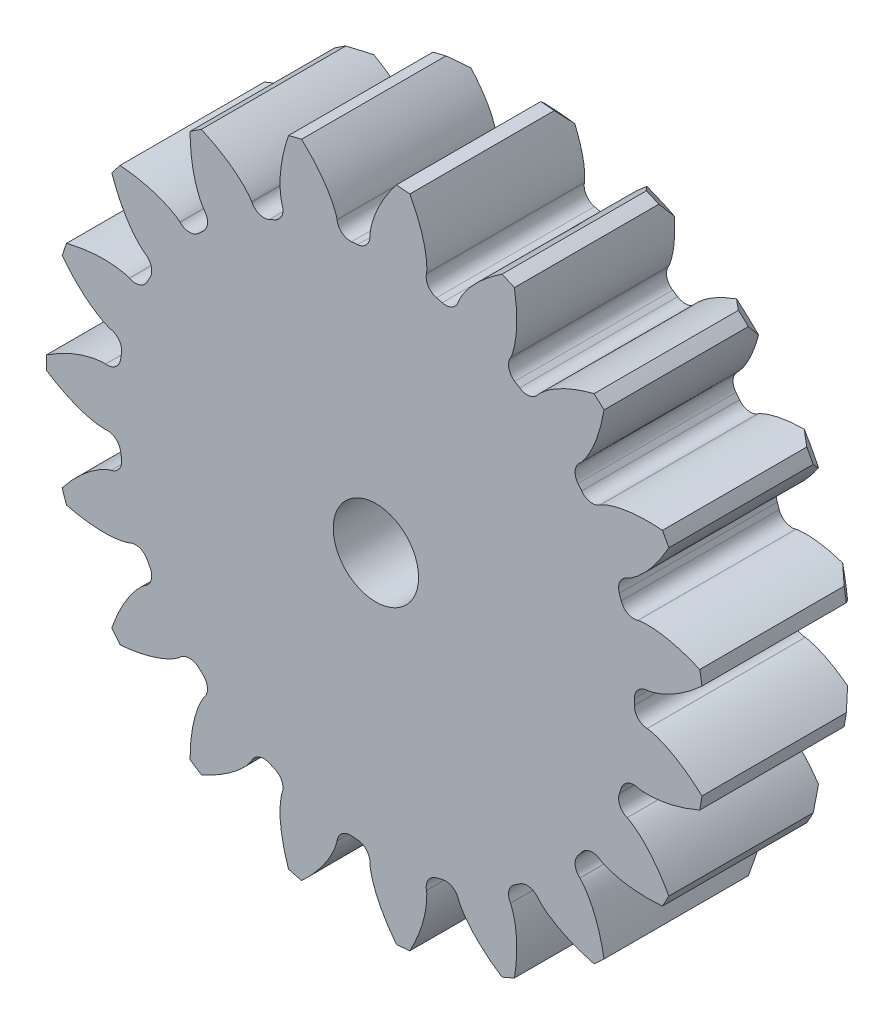
from build123d import *

# Parameters (mm, degrees)
SKETCH1_R                = 10.5
BOSS_EXTRUDE1_DEPTH      = 5
CUT_EXTRUDE1_DEPTH       = 16.668439616
FILLET1_R                = 0.355654565
FILLET2_R                = 0.355654565
CIRPATTERN1_COUNT        = 19
FILLET1_OF_CIRPATTERN1_R = 0.355654565
FILLET2_OF_CIRPATTERN1_R = 0.355654565
SKETCH4_R                = 1.35
BORE_DEPTH               = 16.656347018
SKETCH5_R                = 21
TOLERANCE_DEPTH          = 16.656347018


with BuildPart() as part:
    # Sketch1 → Boss-Extrude1 (new body)
    with BuildSketch(Plane.XY):
        Circle(SKETCH1_R)
    extrude(amount=BOSS_EXTRUDE1_DEPTH)

    # Sketch2 → Cut-Extrude1 (cut, through all)
    with BuildSketch(Plane.XY.offset(5)):
        with BuildLine():
            Line((8.238547136, 0.434558502), (8.597971457, 0.45351705))
            add(Edge.make_bspline(
                [(8.597971457, 0.45351705), (8.601066166, 0.453726154), (8.609736191, 0.454454149), (8.626084978, 0.45638906), (8.652681425, 0.460337865), (8.701902798, 0.469368327), (8.760584055, 0.482995815), (8.826391795, 0.501123817), (8.896585541, 0.523329462), (8.956241339, 0.543998434), (9.015389578, 0.566175785), (9.073967367, 0.589669509), (9.144489943, 0.619774692), (9.228431798, 0.658157785), (9.325567082, 0.706321248), (9.434519939, 0.764819582), (9.5441621, 0.828535043), (9.650866717, 0.894583196), (9.75722015, 0.965119417), (9.859083036, 1.036059663), (9.963278973, 1.113575273), (10.058647067, 1.187080808), (10.163607324, 1.273605914), (10.247769209, 1.34465728), (10.333065488, 1.421484929), (10.37433401, 1.459381335), (10.395319963, 1.478960066)],
                knots=[0, 0, 0, 0, 0, 0.005376749, 0.015083688, 0.02853182, 0.04661014, 0.092110525, 0.119476176, 0.146842496, 0.174208854, 0.201574956, 0.228941013, 0.256307345, 0.307035032, 0.361767352, 0.416499661, 0.471231937, 0.525964282, 0.580696616, 0.635428982, 0.690161387, 0.744893688, 0.799626082, 0.854358408, 0.909090915, 0.909090915, 0.909090915, 0.909090915, 0.909090915], degree=4))
            ThreePointArc((10.395319963, 1.478960066), (10.5, 0), (10.395319963, -1.478960066))
            add(Edge.make_bspline(
                [(8.597971457, -0.45351705), (8.601066166, -0.453726154), (8.609736191, -0.454454149), (8.626084978, -0.45638906), (8.652681425, -0.460337865), (8.701902798, -0.469368327), (8.760584055, -0.482995815), (8.826391795, -0.501123817), (8.896585541, -0.523329462), (8.956241339, -0.543998434), (9.015389578, -0.566175785), (9.073967367, -0.589669509), (9.144489943, -0.619774692), (9.228431798, -0.658157785), (9.325567082, -0.706321248), (9.434519939, -0.764819582), (9.5441621, -0.828535043), (9.650866717, -0.894583196), (9.75722015, -0.965119417), (9.859083036, -1.036059663), (9.963278973, -1.113575273), (10.058647067, -1.187080808), (10.163607324, -1.273605914), (10.247769209, -1.34465728), (10.333065488, -1.421484929), (10.37433401, -1.459381335), (10.395319963, -1.478960066)],
                knots=[0, 0, 0, 0, 0, 0.005376749, 0.015083688, 0.02853182, 0.04661014, 0.092110525, 0.119476176, 0.146842496, 0.174208854, 0.201574956, 0.228941013, 0.256307345, 0.307035032, 0.361767352, 0.416499661, 0.471231937, 0.525964282, 0.580696616, 0.635428982, 0.690161387, 0.744893688, 0.799626082, 0.854358408, 0.909090915, 0.909090915, 0.909090915, 0.909090915, 0.909090915], degree=4))
            Line((8.597971457, -0.45351705), (8.238547136, -0.434558502))
            ThreePointArc((8.238547136, -0.434558502), (8.25, 0), (8.238547136, 0.434558502))
        make_face()
    cut_extrude1 = extrude(amount=-CUT_EXTRUDE1_DEPTH, mode=Mode.SUBTRACT)

    # Fillet1
    fillet1_edges = [part.edges().sort_by_distance(p)[0] for p in [
        (8.238547136, 0.434558502, 2.5),
    ]]
    fillet(fillet1_edges, radius=FILLET1_R)

    # Fillet2
    fillet2_edges = [part.edges().sort_by_distance(p)[0] for p in [
        (8.238547136, -0.434558502, 2.5),
    ]]
    fillet(fillet2_edges, radius=FILLET2_R)

    # CirPattern1: Cut-Extrude1 ×19 about axis
    cirpattern1_axis = Axis((0, 0, 5), (0, 0, -1))
    for i in range(1, CIRPATTERN1_COUNT):
        add(cut_extrude1.rotate(cirpattern1_axis, i * 360 / CIRPATTERN1_COUNT), mode=Mode.SUBTRACT)

    # Fillet1 of CirPattern1
    fillet1_of_cirpattern1_edges = [part.edges().sort_by_distance(p)[0] for p in [
        (7.933260843, -2.264038958, 2.5),
        (6.76828264, -4.717292667, 2.5),
        (4.869855992, -6.659354519, 2.5),
        (2.443704884, -7.879771979, 2.5),
        (-0.247259566, -8.246293877, 2.5),
        (-2.911429605, -7.719201879, 2.5),
        (-5.260101071, -6.355614582, 2.5),
        (-7.038758968, -4.303297828, 2.5),
        (-8.054658112, -1.784651981, 2.5),
        (-8.19771007, 0.9273886, 2.5),
        (-7.45241294, 3.538932236, 2.5),
        (-5.899531233, 5.766977652, 2.5),
        (-3.707343775, 7.370081555, 2.5),
        (-1.113408095, 8.174522764, 2.5),
        (1.601182629, 8.09312759, 2.5),
        (4.142260371, 7.134716464, 2.5),
        (6.234459927, 5.403148103, 2.5),
        (7.651059013, 3.086064806, 2.5),
    ]]
    fillet(fillet1_of_cirpattern1_edges, radius=FILLET1_OF_CIRPATTERN1_R)

    # Fillet2 of CirPattern1
    fillet2_of_cirpattern1_edges = [part.edges().sort_by_distance(p)[0] for p in [
        (7.651059013, -3.086064806, 2.5),
        (6.234459927, -5.403148103, 2.5),
        (4.142260371, -7.134716464, 2.5),
        (1.601182629, -8.09312759, 2.5),
        (-1.113408095, -8.174522764, 2.5),
        (-3.707343775, -7.370081555, 2.5),
        (-5.899531233, -5.766977652, 2.5),
        (-7.45241294, -3.538932236, 2.5),
        (-8.19771007, -0.9273886, 2.5),
        (-8.054658112, 1.784651981, 2.5),
        (-7.038758968, 4.303297828, 2.5),
        (-5.260101071, 6.355614582, 2.5),
        (-2.911429605, 7.719201879, 2.5),
        (-0.247259566, 8.246293877, 2.5),
        (2.443704884, 7.879771979, 2.5),
        (4.869855992, 6.659354519, 2.5),
        (6.76828264, 4.717292667, 2.5),
        (7.933260843, 2.264038958, 2.5),
    ]]
    fillet(fillet2_of_cirpattern1_edges, radius=FILLET2_OF_CIRPATTERN1_R)

    # Sketch4 → Bore (cut, through all)
    with BuildSketch(Plane.XY.offset(5)):
        Circle(SKETCH4_R)
    extrude(amount=-BORE_DEPTH, mode=Mode.SUBTRACT)

    # Sketch5 → TOLERANCE (cut, through all)
    with BuildSketch(Plane.XY.offset(5)):
        Circle(SKETCH5_R)
        with BuildLine():
            Line((8.298039786, 2.295346858), (8.287400812, 2.292310648))
            ThreePointArc((8.287400812, 2.292310648), (7.971493069, 2.325401646), (7.766453609, 2.567995002))
            ThreePointArc((7.766453609, 2.567995002), (7.736785037, 2.656041658), (7.706118334, 2.743745655))
            ThreePointArc((7.706118334, 2.743745655), (7.718919354, 3.061123743), (7.94789004, 3.281271742))
            Line((7.94789004, 3.281271742), (7.958150564, 3.285410338))
            add(Edge.make_bspline(
                [(7.958150564, 3.285410338), (7.997359223, 3.302019925), (8.032960577, 3.324051928), (8.103780193, 3.368691785), (8.138229903, 3.392454909), (8.239536329, 3.466814827), (8.304462579, 3.520587408), (8.49120292, 3.688881504), (8.606043306, 3.811072511), (8.929053068, 4.19750903), (9.112816382, 4.479727113), (9.272799843, 4.774943253)],
                knots=[0, 0, 0, 0, 0.0625, 0.0625, 0.125, 0.125, 0.25, 0.25, 0.5, 0.5, 1, 1, 1, 1], degree=3))
            ThreePointArc((9.272799843, 4.774943253), (9.172911225, 4.964131309), (9.069163222, 5.151230771))
            add(Edge.make_bspline(
                [(9.069163222, 5.151230771), (8.734232229, 5.178789212), (8.397206051, 5.179237037), (7.897522299, 5.120219043), (7.731406922, 5.090702949), (7.488545768, 5.026376771), (7.368890833, 4.989276062), (7.252932669, 4.94189555), (7.176802326, 4.907040879), (7.138839803, 4.889328103), (7.103131195, 4.865347748)],
                knots=[0, 0, 0, 0, 0.5, 0.5, 0.75, 0.75, 0.875, 0.9375, 0.9375, 1, 1, 1, 1], degree=3))
            Line((7.103131195, 4.865347748), (7.094054527, 4.859021579))
            ThreePointArc((7.094054527, 4.859021579), (6.784518906, 4.787744539), (6.511819117, 4.950617314))
            ThreePointArc((6.511819117, 4.950617314), (6.455169367, 5.02425999), (6.397686829, 5.09725448))
            ThreePointArc((6.397686829, 5.09725448), (6.306741758, 5.401592632), (6.451824242, 5.684159065))
            Line((6.451824242, 5.684159065), (6.460185023, 5.691405008))
            add(Edge.make_bspline(
                [(6.460185023, 5.691405008), (6.491876124, 5.719845673), (6.518394719, 5.752243661), (6.570882595, 5.817459899), (6.595749851, 5.851121275), (6.667422589, 5.954346309), (6.711371028, 6.026286863), (6.833348258, 6.24609681), (6.90229092, 6.398955784), (7.08232339, 6.869335205), (7.164493838, 7.195929784), (7.219952431, 7.527096844)],
                knots=[0, 0, 0, 0, 0.0625, 0.0625, 0.125, 0.125, 0.25, 0.25, 0.5, 0.5, 1, 1, 1, 1], degree=3))
            ThreePointArc((7.219952431, 7.527096844), (7.064046792, 7.673600388), (6.905169046, 7.816875363))
            add(Edge.make_bspline(
                [(6.905169046, 7.816875363), (6.579437327, 7.734188697), (6.260526749, 7.625180036), (5.807080352, 7.407112751), (5.659549424, 7.325258345), (5.450733833, 7.185560649), (5.349608713, 7.111618265), (5.255317909, 7.029153405), (5.194629811, 6.971467775), (5.164475532, 6.942388315), (5.138488123, 6.908112716)],
                knots=[0, 0, 0, 0, 0.5, 0.5, 0.75, 0.75, 0.875, 0.9375, 0.9375, 1, 1, 1, 1], degree=3))
            Line((5.138488123, 6.908112716), (5.131957357, 6.899182126))
            ThreePointArc((5.131957357, 6.899182126), (4.862336848, 6.731261021), (4.551527981, 6.796763424))
            ThreePointArc((4.551527981, 6.796763424), (4.474035933, 6.848021792), (4.395966686, 6.89839669))
            ThreePointArc((4.395966686, 6.89839669), (4.211130833, 7.156715145), (4.256603177, 7.471079555))
            Line((4.256603177, 7.471079555), (4.262158194, 7.480647634))
            add(Edge.make_bspline(
                [(4.262158194, 7.480647634), (4.282897516, 7.517837389), (4.29745965, 7.557090538), (4.32592791, 7.635815966), (4.338517959, 7.675727861), (4.372790157, 7.796631978), (4.390998288, 7.878944629), (4.434994282, 8.126450608), (4.450568213, 8.293412907), (4.468114079, 8.796762321), (4.439787219, 9.132341806), (4.384711143, 9.463572697)],
                knots=[0, 0, 0, 0, 0.0625, 0.0625, 0.125, 0.125, 0.25, 0.25, 0.5, 0.5, 1, 1, 1, 1], degree=3))
            ThreePointArc((4.384711143, 9.463572697), (4.189683279, 9.551515797), (3.992892659, 9.635440219))
            add(Edge.make_bspline(
                [(3.992892659, 9.635440219), (3.7116583, 9.451468828), (3.445422231, 9.244816461), (3.087351142, 8.891330859), (2.974391929, 8.766008337), (2.822250311, 8.566077536), (2.750613482, 8.463306281), (2.688207909, 8.354693421), (2.649538553, 8.280427964), (2.630460202, 8.243133031), (2.617010131, 8.202276481)],
                knots=[0, 0, 0, 0, 0.5, 0.5, 0.75, 0.75, 0.875, 0.9375, 0.9375, 1, 1, 1, 1], degree=3))
            Line((2.617010131, 8.202276481), (2.613732978, 8.191709239))
            ThreePointArc((2.613732978, 8.191709239), (2.413245145, 7.945340926), (2.098008165, 7.906374753))
            ThreePointArc((2.098008165, 7.906374753), (2.008071285, 7.929694175), (1.917875342, 7.951990579))
            ThreePointArc((1.917875342, 7.951990579), (1.65917854, 8.136296524), (1.60011311, 8.44839265))
            Line((1.60011311, 8.44839265), (1.602260391, 8.459246014))
            add(Edge.make_bspline(
                [(1.602260391, 8.459246014), (1.609800505, 8.501154773), (1.610828146, 8.543009395), (1.612191813, 8.626712892), (1.611140327, 8.668550231), (1.60429806, 8.794031595), (1.59479275, 8.87779649), (1.55603986, 9.126177389), (1.516557382, 9.289150057), (1.369715277, 9.770923744), (1.233960764, 10.079122891), (1.074318368, 10.374523606)],
                knots=[0, 0, 0, 0, 0.0625, 0.0625, 0.125, 0.125, 0.25, 0.25, 0.5, 0.5, 1, 1, 1, 1], degree=3))
            ThreePointArc((1.074318368, 10.374523606), (0.861302573, 10.394376262), (0.647924397, 10.409855617))
            add(Edge.make_bspline(
                [(0.647924397, 10.409855617), (0.441663504, 10.144535657), (0.256952753, 9.862633575), (0.033059531, 9.412035305), (-0.033087084, 9.256825307), (-0.112067825, 9.018327005), (-0.146453401, 8.89786374), (-0.170211129, 8.774872768), (-0.182671319, 8.692075299), (-0.188606307, 8.650606377), (-0.188061516, 8.607596317)],
                knots=[0, 0, 0, 0, 0.5, 0.5, 0.75, 0.75, 0.875, 0.9375, 0.9375, 1, 1, 1, 1], degree=3))
            Line((-0.188061516, 8.607596317), (-0.187729926, 8.596537547))
            ThreePointArc((-0.187729926, 8.596537547), (-0.297359115, 8.298419857), (-0.582863391, 8.159207699))
            ThreePointArc((-0.582863391, 8.159207699), (-0.675499046, 8.152061153), (-0.768047555, 8.143862901))
            ThreePointArc((-0.768047555, 8.143862901), (-1.072571492, 8.234183928), (-1.229774041, 8.51019131))
            Line((-1.229774041, 8.51019131), (-1.231267187, 8.52115383))
            add(Edge.make_bspline(
                [(-1.231267187, 8.52115383), (-1.237743369, 8.563240128), (-1.250361582, 8.603160626), (-1.276250284, 8.682771618), (-1.290829359, 8.722000678), (-1.338044625, 8.838461435), (-1.374233328, 8.914601348), (-1.491535626, 9.136941241), (-1.581795973, 9.278263661), (-1.877113428, 9.686253968), (-2.105584486, 9.933674616), (-2.352493473, 10.161233904)],
                knots=[0, 0, 0, 0, 0.0625, 0.0625, 0.125, 0.125, 0.25, 0.25, 0.5, 0.5, 1, 1, 1, 1], degree=3))
            ThreePointArc((-2.352493473, 10.161233904), (-2.560413631, 10.110844774), (-2.767256528, 10.056201634))
            add(Edge.make_bspline(
                [(-2.767256528, 10.056201634), (-2.876192386, 9.738284638), (-2.959361543, 9.411681306), (-3.024814593, 8.912799683), (-3.036980598, 8.74452162), (-3.034241672, 8.493300809), (-3.027649785, 8.368199598), (-3.010185151, 8.244158494), (-2.995085919, 8.161801404), (-2.987234396, 8.120652295), (-2.972753779, 8.080149532)],
                knots=[0, 0, 0, 0, 0.5, 0.5, 0.75, 0.75, 0.875, 0.9375, 0.9375, 1, 1, 1, 1], degree=3))
            Line((-2.972753779, 8.080149532), (-2.96884938, 8.069797624))
            ThreePointArc((-2.96884938, 8.069797624), (-2.9757399, 7.752236233), (-3.200572653, 7.527863886))
            ThreePointArc((-3.200572653, 7.527863886), (-3.285868574, 7.491025812), (-3.370740581, 7.453221313))
            ThreePointArc((-3.370740581, 7.453221313), (-3.688091761, 7.439769736), (-3.926396093, 7.649778693))
            Line((-3.926396093, 7.649778693), (-3.931367861, 7.65966241))
            add(Edge.make_bspline(
                [(-3.931367861, 7.65966241), (-3.951158543, 7.697365543), (-3.976055232, 7.731025911), (-4.026390859, 7.797917312), (-4.052917655, 7.830287016), (-4.135389414, 7.925106836), (-4.194339901, 7.985370825), (-4.377480083, 8.157575736), (-4.50873719, 8.261933431), (-4.920527767, 8.551928277), (-5.216956986, 8.711758561), (-5.524376143, 8.846816842)],
                knots=[0, 0, 0, 0, 0.0625, 0.0625, 0.125, 0.125, 0.25, 0.25, 0.5, 0.5, 1, 1, 1, 1], degree=3))
            ThreePointArc((-5.524376143, 8.846816842), (-5.704669289, 8.731646368), (-5.882562269, 8.612802166))
            add(Edge.make_bspline(
                [(-5.882562269, 8.612802166), (-5.882368202, 8.276739375), (-5.854983096, 7.940827331), (-5.754903122, 7.447723919), (-5.71177014, 7.28461333), (-5.627608354, 7.047893684), (-5.580753336, 6.931711183), (-5.523958903, 6.820061726), (-5.482936486, 6.747069683), (-5.462149287, 6.710699531), (-5.435302044, 6.677093168)],
                knots=[0, 0, 0, 0, 0.5, 0.5, 0.75, 0.75, 0.875, 0.9375, 0.9375, 1, 1, 1, 1], degree=3))
            Line((-5.435302044, 6.677093168), (-5.428247936, 6.668569912))
            ThreePointArc((-5.428247936, 6.668569912), (-5.331653094, 6.365977524), (-5.471450207, 6.080759215))
            ThreePointArc((-5.471450207, 6.080759215), (-5.540163256, 6.018221589), (-5.608161563, 5.954907546))
            ThreePointArc((-5.608161563, 5.954907546), (-5.903950061, 5.839141053), (-6.197532203, 5.960393856))
            Line((-6.197532203, 5.960393856), (-6.205443825, 5.968127715))
            add(Edge.make_bspline(
                [(-6.205443825, 5.968127715), (-6.236404381, 5.997361964), (-6.270881602, 6.021114579), (-6.340209508, 6.068037669), (-6.375809435, 6.090040256), (-6.484600591, 6.15294394), (-6.559924665, 6.190801468), (-6.789056649, 6.294210323), (-6.947086772, 6.350294517), (-7.430726572, 6.49086846), (-7.762991247, 6.545788288), (-8.097606938, 6.573709902)],
                knots=[0, 0, 0, 0, 0.0625, 0.0625, 0.125, 0.125, 0.25, 0.25, 0.5, 0.5, 1, 1, 1, 1], degree=3))
            ThreePointArc((-8.097606938, 6.573709902), (-8.230735513, 6.406238593), (-8.360401111, 6.236071942))
            add(Edge.make_bspline(
                [(-8.360401111, 6.236071942), (-8.251098149, 5.918280973), (-8.116126381, 5.609461499), (-7.8613586, 5.175571705), (-7.767600761, 5.035304154), (-7.611136349, 4.838737919), (-7.529095669, 4.744064306), (-7.439125996, 4.656905446), (-7.376625808, 4.601188271), (-7.345155548, 4.573538347), (-7.308850995, 4.550470154)],
                knots=[0, 0, 0, 0, 0.5, 0.5, 0.75, 0.75, 0.875, 0.9375, 0.9375, 1, 1, 1, 1], degree=3))
            Line((-7.308850995, 4.550470154), (-7.299411601, 4.544699177))
            ThreePointArc((-7.299411601, 4.544699177), (-7.109798947, 4.289866373), (-7.149411232, 3.974709931))
            ThreePointArc((-7.149411232, 3.974709931), (-7.194095285, 3.893249675), (-7.23785122, 3.811287147))
            ThreePointArc((-7.23785122, 3.811287147), (-7.480023762, 3.605750834), (-7.797069535, 3.62510786))
            Line((-7.797069535, 3.62510786), (-7.807063663, 3.629853778))
            add(Edge.make_bspline(
                [(-7.807063663, 3.629853778), (-7.845839036, 3.647451158), (-7.886160648, 3.658722056), (-7.966968079, 3.680591988), (-8.007783332, 3.689843137), (-8.131104676, 3.714014096), (-8.214639803, 3.725362712), (-8.464933584, 3.748769556), (-8.632611708, 3.750502656), (-9.135690854, 3.726422329), (-9.467784951, 3.670480286), (-9.793336374, 3.588239493)],
                knots=[0, 0, 0, 0, 0.0625, 0.0625, 0.125, 0.125, 0.25, 0.25, 0.5, 0.5, 1, 1, 1, 1], degree=3))
            ThreePointArc((-9.793336374, 3.588239493), (-9.864873831, 3.386615464), (-9.932260768, 3.18356656))
            add(Edge.make_bspline(
                [(-9.932260768, 3.18356656), (-9.725693583, 2.918484996), (-9.497761439, 2.670223475), (-9.115913893, 2.34256599), (-8.981691313, 2.240341642), (-8.769879621, 2.105229819), (-8.66154366, 2.042324449), (-8.548148357, 1.989101202), (-8.470943264, 1.956696714), (-8.432200234, 1.940763316), (-8.390372532, 1.930733091)],
                knots=[0, 0, 0, 0, 0.5, 0.5, 0.75, 0.75, 0.875, 0.9375, 0.9375, 1, 1, 1, 1], degree=3))
            Line((-8.390372532, 1.930733091), (-8.379570757, 1.928339767))
            ThreePointArc((-8.379570757, 1.928339767), (-8.117487763, 1.748881636), (-8.052622616, 1.437939151))
            ThreePointArc((-8.052622616, 1.437939151), (-8.068435462, 1.346383748), (-8.08320739, 1.254654648))
            ThreePointArc((-8.08320739, 1.254654648), (-8.245520824, 0.981621563), (-8.551673399, 0.896985177))
            Line((-8.551673399, 0.896985177), (-8.562667015, 0.89822886))
            add(Edge.make_bspline(
                [(-8.562667015, 0.89822886), (-8.605055291, 0.902282423), (-8.646851821, 0.899850227), (-8.730382038, 0.894297056), (-8.771989651, 0.889794261), (-8.896477402, 0.872613195), (-8.979171255, 0.856223101), (-9.223503619, 0.797091439), (-9.382659216, 0.744285638), (-9.850661277, 0.558160518), (-10.146597248, 0.397418792), (-10.427805855, 0.213927657)],
                knots=[0, 0, 0, 0, 0.0625, 0.0625, 0.125, 0.125, 0.25, 0.25, 0.5, 0.5, 1, 1, 1, 1], degree=3))
            ThreePointArc((-10.427805855, 0.213927657), (-10.43, 0), (-10.427805855, -0.213927657))
            add(Edge.make_bspline(
                [(-10.427805855, -0.213927657), (-10.146359207, -0.397574115), (-9.850166671, -0.558374696), (-9.382618467, -0.744293099), (-9.222476245, -0.797396649), (-8.978270358, -0.856412597), (-8.855378998, -0.880732952), (-8.730846205, -0.894253022), (-8.647302577, -0.899833292), (-8.605485185, -0.902323534), (-8.562667015, -0.89822886)],
                knots=[0, 0, 0, 0, 0.5, 0.5, 0.75, 0.75, 0.875, 0.9375, 0.9375, 1, 1, 1, 1], degree=3))
            Line((-8.562667015, -0.89822886), (-8.551673399, -0.896985177))
            ThreePointArc((-8.551673399, -0.896985177), (-8.245520824, -0.981621563), (-8.08320739, -1.254654648))
            ThreePointArc((-8.08320739, -1.254654648), (-8.068435462, -1.346383748), (-8.052622616, -1.437939151))
            ThreePointArc((-8.052622616, -1.437939151), (-8.117487763, -1.748881636), (-8.379570757, -1.928339767))
            Line((-8.379570757, -1.928339767), (-8.390372532, -1.930733091))
            add(Edge.make_bspline(
                [(-8.390372532, -1.930733091), (-8.431780284, -1.940662613), (-8.47052243, -1.956534337), (-8.547723638, -1.988908839), (-8.58561478, -2.00667763), (-8.697778759, -2.063348885), (-8.770670176, -2.105701569), (-8.982563919, -2.240963903), (-9.115950011, -2.342586278), (-9.498159701, -2.670586647), (-9.725868293, -2.918709195), (-9.932260768, -3.18356656)],
                knots=[0, 0, 0, 0, 0.0625, 0.0625, 0.125, 0.125, 0.25, 0.25, 0.5, 0.5, 1, 1, 1, 1], degree=3))
            ThreePointArc((-9.932260768, -3.18356656), (-9.864873831, -3.386615464), (-9.793336374, -3.588239493))
            add(Edge.make_bspline(
                [(-9.793336374, -3.588239493), (-9.467509374, -3.670549902), (-9.135153504, -3.726464305), (-8.632570744, -3.750496482), (-8.463862775, -3.748724641), (-8.21372619, -3.72524942), (-8.089596616, -3.708349272), (-7.967421394, -3.680701055), (-7.886592479, -3.658852399), (-7.846232289, -3.647629628), (-7.807063663, -3.629853778)],
                knots=[0, 0, 0, 0, 0.5, 0.5, 0.75, 0.75, 0.875, 0.9375, 0.9375, 1, 1, 1, 1], degree=3))
            Line((-7.807063663, -3.629853778), (-7.797069535, -3.62510786))
            ThreePointArc((-7.797069535, -3.62510786), (-7.480023762, -3.605750834), (-7.23785122, -3.811287147))
            ThreePointArc((-7.23785122, -3.811287147), (-7.194095285, -3.893249675), (-7.149411232, -3.974709931))
            ThreePointArc((-7.149411232, -3.974709931), (-7.109798947, -4.289866373), (-7.299411601, -4.544699177))
            Line((-7.299411601, -4.544699177), (-7.308850995, -4.550470154))
            add(Edge.make_bspline(
                [(-7.308850995, -4.550470154), (-7.344791051, -4.573306742), (-7.376280499, -4.600898047), (-7.438786749, -4.6565856), (-7.468855329, -4.685694863), (-7.556540827, -4.775715097), (-7.611730892, -4.8394408), (-7.768224039, -5.036176034), (-7.861386174, -5.175602622), (-8.116385143, -5.609934309), (-8.251190595, -5.918549753), (-8.360401111, -6.236071942)],
                knots=[0, 0, 0, 0, 0.0625, 0.0625, 0.125, 0.125, 0.25, 0.25, 0.5, 0.5, 1, 1, 1, 1], degree=3))
            ThreePointArc((-8.360401111, -6.236071942), (-8.230735513, -6.406238593), (-8.097606938, -6.573709902))
            add(Edge.make_bspline(
                [(-8.097606938, -6.573709902), (-7.762707997, -6.545764653), (-7.430204708, -6.490733684), (-6.947050033, -6.350275376), (-6.788058443, -6.29382015), (-6.559097339, -6.190397665), (-6.447180918, -6.134108407), (-6.340602847, -6.068288017), (-6.271247713, -6.021378076), (-6.236718377, -5.997658453), (-6.205443825, -5.968127715)],
                knots=[0, 0, 0, 0, 0.5, 0.5, 0.75, 0.75, 0.875, 0.9375, 0.9375, 1, 1, 1, 1], degree=3))
            Line((-6.205443825, -5.968127715), (-6.197532203, -5.960393856))
            ThreePointArc((-6.197532203, -5.960393856), (-5.903950061, -5.839141053), (-5.608161563, -5.954907546))
            ThreePointArc((-5.608161563, -5.954907546), (-5.540163256, -6.018221589), (-5.471450207, -6.080759215))
            ThreePointArc((-5.471450207, -6.080759215), (-5.331653094, -6.365977524), (-5.428247936, -6.668569912))
            Line((-5.428247936, -6.668569912), (-5.435302044, -6.677093168))
            add(Edge.make_bspline(
                [(-5.435302044, -6.677093168), (-5.461879741, -6.710362124), (-5.482704122, -6.746683063), (-5.523741892, -6.819649057), (-5.542729511, -6.856944351), (-5.596434445, -6.970558476), (-5.627942457, -7.048751529), (-5.712076549, -7.285640347), (-5.754919163, -7.447762114), (-5.855074316, -7.941358542), (-5.882368366, -8.277023609), (-5.882562269, -8.612802166)],
                knots=[0, 0, 0, 0, 0.0625, 0.0625, 0.125, 0.125, 0.25, 0.25, 0.5, 0.5, 1, 1, 1, 1], degree=3))
            ThreePointArc((-5.882562269, -8.612802166), (-5.704669289, -8.731646368), (-5.524376143, -8.846816842))
            add(Edge.make_bspline(
                [(-5.524376143, -8.846816842), (-5.216696758, -8.711644235), (-4.92007794, -8.551631354), (-4.508708656, -8.261903399), (-4.376662651, -8.156882588), (-4.193688518, -7.98472027), (-4.106113129, -7.895141715), (-4.026681598, -7.798281813), (-3.976315949, -7.731394007), (-3.951359257, -7.697747921), (-3.931367861, -7.65966241)],
                knots=[0, 0, 0, 0, 0.5, 0.5, 0.75, 0.75, 0.875, 0.9375, 0.9375, 1, 1, 1, 1], degree=3))
            Line((-3.931367861, -7.65966241), (-3.926396093, -7.649778693))
            ThreePointArc((-3.926396093, -7.649778693), (-3.688091761, -7.439769736), (-3.370740581, -7.453221313))
            ThreePointArc((-3.370740581, -7.453221313), (-3.285868574, -7.491025812), (-3.200572653, -7.527863886))
            ThreePointArc((-3.200572653, -7.527863886), (-2.9757399, -7.752236233), (-2.96884938, -8.069797624))
            Line((-2.96884938, -8.069797624), (-2.972753779, -8.080149532))
            add(Edge.make_bspline(
                [(-2.972753779, -8.080149532), (-2.987089011, -8.120245647), (-2.994991681, -8.161360284), (-3.010113891, -8.243697721), (-3.015962946, -8.285137523), (-3.029867552, -8.410033684), (-3.034279131, -8.494220657), (-3.036936932, -8.745592481), (-3.024817364, -8.912841017), (-2.959275336, -9.412213355), (-2.876100251, -9.738553525), (-2.767256528, -10.056201634)],
                knots=[0, 0, 0, 0, 0.0625, 0.0625, 0.125, 0.125, 0.25, 0.25, 0.5, 0.5, 1, 1, 1, 1], degree=3))
            ThreePointArc((-2.767256528, -10.056201634), (-2.560413631, -10.110844774), (-2.352493473, -10.161233904))
            add(Edge.make_bspline(
                [(-2.352493473, -10.161233904), (-2.105375479, -9.933481989), (-1.876784385, -9.685827075), (-1.581778737, -9.278225991), (-1.49098755, -9.13602023), (-1.373828473, -8.913774537), (-1.320084269, -8.800613913), (-1.276406917, -8.683210771), (-1.250488653, -8.603593432), (-1.237809049, -8.563666959), (-1.231267187, -8.52115383)],
                knots=[0, 0, 0, 0, 0.5, 0.5, 0.75, 0.75, 0.875, 0.9375, 0.9375, 1, 1, 1, 1], degree=3))
            Line((-1.231267187, -8.52115383), (-1.229774041, -8.51019131))
            ThreePointArc((-1.229774041, -8.51019131), (-1.072571492, -8.234183928), (-0.768047555, -8.143862901))
            ThreePointArc((-0.768047555, -8.143862901), (-0.675499046, -8.152061153), (-0.582863391, -8.159207699))
            ThreePointArc((-0.582863391, -8.159207699), (-0.297359115, -8.298419857), (-0.187729926, -8.596537547))
            Line((-0.187729926, -8.596537547), (-0.188061516, -8.607596317))
            add(Edge.make_bspline(
                [(-0.188061516, -8.607596317), (-0.188600838, -8.650174557), (-0.182725418, -8.691627481), (-0.170293344, -8.774413823), (-0.162369999, -8.815507487), (-0.134967498, -8.938151248), (-0.11180458, -9.019209176), (-0.032698076, -9.257823967), (0.033070332, -9.412075298), (0.257207044, -9.863108804), (0.441837955, -10.144760058), (0.647924397, -10.409855617)],
                knots=[0, 0, 0, 0, 0.0625, 0.0625, 0.125, 0.125, 0.25, 0.25, 0.5, 0.5, 1, 1, 1, 1], degree=3))
            ThreePointArc((0.647924397, -10.409855617), (0.861302573, -10.394376262), (1.074318368, -10.374523606))
            add(Edge.make_bspline(
                [(1.074318368, -10.374523606), (1.234095901, -10.078872836), (1.36988788, -9.770413141), (1.516561453, -9.289108831), (1.556259188, -9.12512832), (1.594907204, -8.876883021), (1.608996204, -8.752403038), (1.612186259, -8.627179109), (1.610848492, -8.54346001), (1.609876975, -8.501579803), (1.602260391, -8.459246014)],
                knots=[0, 0, 0, 0, 0.5, 0.5, 0.75, 0.75, 0.875, 0.9375, 0.9375, 1, 1, 1, 1], degree=3))
            Line((1.602260391, -8.459246014), (1.60011311, -8.44839265))
            ThreePointArc((1.60011311, -8.44839265), (1.65917854, -8.136296524), (1.917875342, -7.951990579))
            ThreePointArc((1.917875342, -7.951990579), (2.008071285, -7.929694175), (2.098008165, -7.906374753))
            ThreePointArc((2.098008165, -7.906374753), (2.413245145, -7.945340926), (2.613732978, -8.191709239))
            Line((2.613732978, -8.191709239), (2.617010131, -8.202276481))
            add(Edge.make_bspline(
                [(2.617010131, -8.202276481), (2.630325163, -8.242722831), (2.649341979, -8.280021976), (2.68798113, -8.354286038), (2.708818257, -8.390580428), (2.774558379, -8.497681434), (2.822785733, -8.566826433), (2.975084124, -8.766826577), (3.087374343, -8.891365178), (3.445817051, -9.245183373), (3.711896162, -9.451624426), (3.992892659, -9.635440219)],
                knots=[0, 0, 0, 0, 0.0625, 0.0625, 0.125, 0.125, 0.25, 0.25, 0.5, 0.5, 1, 1, 1, 1], degree=3))
            ThreePointArc((3.992892659, -9.635440219), (4.189683279, -9.551515797), (4.384711143, -9.463572697))
            add(Edge.make_bspline(
                [(4.384711143, -9.463572697), (4.439833841, -9.132061422), (4.468111537, -8.79622334), (4.450558677, -8.293372594), (4.434861094, -8.125387165), (4.390809938, -7.878043492), (4.363716972, -7.755733487), (4.326074038, -7.636258726), (4.297625208, -7.557510131), (4.28310785, -7.51821456), (4.262158194, -7.480647634)],
                knots=[0, 0, 0, 0, 0.5, 0.5, 0.75, 0.75, 0.875, 0.9375, 0.9375, 1, 1, 1, 1], degree=3))
            Line((4.262158194, -7.480647634), (4.256603177, -7.471079555))
            ThreePointArc((4.256603177, -7.471079555), (4.211130833, -7.156715145), (4.395966686, -6.89839669))
            ThreePointArc((4.395966686, -6.89839669), (4.474035933, -6.848021792), (4.551527981, -6.796763424))
            ThreePointArc((4.551527981, -6.796763424), (4.862336848, -6.731261021), (5.131957357, -6.899182126))
            Line((5.131957357, -6.899182126), (5.138488123, -6.908112716))
            add(Edge.make_bspline(
                [(5.138488123, -6.908112716), (5.164214619, -6.942044188), (5.194312063, -6.971147612), (5.25497114, -7.02884173), (5.286464024, -7.056403786), (5.383417805, -7.136355982), (5.451483411, -7.186095118), (5.660469796, -7.325807495), (5.807113439, -7.407137677), (6.261019312, -7.62539887), (6.579712823, -7.734258631), (6.905169046, -7.816875363)],
                knots=[0, 0, 0, 0, 0.0625, 0.0625, 0.125, 0.125, 0.25, 0.25, 0.5, 0.5, 1, 1, 1, 1], degree=3))
            ThreePointArc((6.905169046, -7.816875363), (7.064046792, -7.673600388), (7.219952431, -7.527096844))
            add(Edge.make_bspline(
                [(7.219952431, -7.527096844), (7.164446893, -7.195649453), (7.082145979, -6.868826252), (6.902268811, -6.398920751), (6.832876987, -6.245134233), (6.710900284, -6.025495709), (6.645561297, -5.918609869), (6.571164569, -5.817831221), (6.518687549, -5.752586762), (6.49219753, -5.720134113), (6.460185023, -5.691405008)],
                knots=[0, 0, 0, 0, 0.5, 0.5, 0.75, 0.75, 0.875, 0.9375, 0.9375, 1, 1, 1, 1], degree=3))
            Line((6.460185023, -5.691405008), (6.451824242, -5.684159065))
            ThreePointArc((6.451824242, -5.684159065), (6.306741758, -5.401592632), (6.397686829, -5.09725448))
            ThreePointArc((6.397686829, -5.09725448), (6.455169367, -5.02425999), (6.511819117, -4.950617314))
            ThreePointArc((6.511819117, -4.950617314), (6.784518906, -4.787744539), (7.094054527, -4.859021579))
            Line((7.094054527, -4.859021579), (7.103131195, -4.865347748))
            add(Edge.make_bspline(
                [(7.103131195, -4.865347748), (7.138481289, -4.88908734), (7.176397838, -4.906841237), (7.252503488, -4.941713358), (7.291239385, -4.957556303), (7.408900378, -5.001695627), (7.489428274, -5.026638893), (7.732455735, -5.0909235), (7.897561688, -5.120231876), (8.397742982, -5.179284079), (8.734515506, -5.178765904), (9.069163222, -5.151230771)],
                knots=[0, 0, 0, 0, 0.0625, 0.0625, 0.125, 0.125, 0.25, 0.25, 0.5, 0.5, 1, 1, 1, 1], degree=3))
            ThreePointArc((9.069163222, -5.151230771), (9.172911225, -4.964131309), (9.272799843, -4.774943253))
            add(Edge.make_bspline(
                [(9.272799843, -4.774943253), (9.112680957, -4.479477215), (8.928720013, -4.197085259), (8.60601102, -3.811046555), (8.490444635, -3.688124104), (8.303760455, -3.519991971), (8.207255938, -3.440113035), (8.104167457, -3.368951431), (8.033348945, -3.324281357), (7.99775687, -3.302188377), (7.958150564, -3.285410338)],
                knots=[0, 0, 0, 0, 0.5, 0.5, 0.75, 0.75, 0.875, 0.9375, 0.9375, 1, 1, 1, 1], degree=3))
            Line((7.958150564, -3.285410338), (7.94789004, -3.281271742))
            ThreePointArc((7.94789004, -3.281271742), (7.718919354, -3.061123743), (7.706118334, -2.743745655))
            ThreePointArc((7.706118334, -2.743745655), (7.736785037, -2.656041658), (7.766453609, -2.567995002))
            ThreePointArc((7.766453609, -2.567995002), (7.971493069, -2.325401646), (8.287400812, -2.292310648))
            Line((8.287400812, -2.292310648), (8.298039786, -2.295346858))
            add(Edge.make_bspline(
                [(8.298039786, -2.295346858), (8.339182747, -2.306322017), (8.380809553, -2.310802475), (8.464114549, -2.319073664), (8.505895824, -2.32148067), (8.631513635, -2.325023942), (8.715777372, -2.322468348), (8.966510113, -2.30435895), (9.132186584, -2.278469501), (9.624440895, -2.171913493), (9.942797904, -2.062073534), (10.25037284, -1.927370395)],
                knots=[0, 0, 0, 0, 0.0625, 0.0625, 0.125, 0.125, 0.25, 0.25, 0.5, 0.5, 1, 1, 1, 1], degree=3))
            ThreePointArc((10.25037284, -1.927370395), (10.287748394, -1.716721577), (10.32079551, -1.50535047))
            add(Edge.make_bspline(
                [(10.32079551, -1.50535047), (10.073414641, -1.277884114), (9.807728691, -1.070524954), (9.377158398, -0.810186331), (9.227940865, -0.731448501), (8.996779334, -0.633042485), (8.87956705, -0.588826575), (8.758958052, -0.554993478), (8.677472333, -0.535738486), (8.636635156, -0.526399291), (8.593727008, -0.52339048)],
                knots=[0, 0, 0, 0, 0.5, 0.5, 0.75, 0.75, 0.875, 0.9375, 0.9375, 1, 1, 1, 1], degree=3))
            Line((8.593727008, -0.52339048), (8.582678628, -0.522807711))
            ThreePointArc((8.582678628, -0.522807711), (8.294632267, -0.388934598), (8.179472345, -0.092909415))
            ThreePointArc((8.179472345, -0.092909415), (8.18, 0), (8.179472345, 0.092909415))
            ThreePointArc((8.179472345, 0.092909415), (8.294632267, 0.388934598), (8.582678628, 0.522807711))
            Line((8.582678628, 0.522807711), (8.593727008, 0.52339048))
            add(Edge.make_bspline(
                [(8.593727008, 0.52339048), (8.636204359, 0.526369083), (8.677030512, 0.53564759), (8.758507464, 0.554873645), (8.798806467, 0.566163415), (8.918768458, 0.603600164), (8.997636753, 0.63337768), (9.22890399, 0.731918648), (9.377197363, 0.810200397), (9.808181298, 1.070817621), (10.07362387, 1.2780765), (10.32079551, 1.50535047)],
                knots=[0, 0, 0, 0, 0.0625, 0.0625, 0.125, 0.125, 0.25, 0.25, 0.5, 0.5, 1, 1, 1, 1], degree=3))
            ThreePointArc((10.32079551, 1.50535047), (10.287748394, 1.716721577), (10.25037284, 1.927370395))
            add(Edge.make_bspline(
                [(10.25037284, 1.927370395), (9.942537544, 2.062187559), (9.623917782, 2.172043341), (9.132145163, 2.278470154), (8.965446515, 2.304490897), (8.714857572, 2.322506977), (8.589639291, 2.32626838), (8.464579633, 2.31910663), (8.381256949, 2.310859964), (8.339600011, 2.306433325), (8.298039786, 2.295346858)],
                knots=[0, 0, 0, 0, 0.5, 0.5, 0.75, 0.75, 0.875, 0.9375, 0.9375, 1, 1, 1, 1], degree=3))
        make_face(mode=Mode.SUBTRACT)
    extrude(amount=-TOLERANCE_DEPTH, mode=Mode.SUBTRACT)

    # Sketch6 → BottomChamfer (revolve, cut)
    with BuildSketch(Plane(origin=(0, 0, 0), x_dir=(1, 0, 0), z_dir=(0, 1, 0))):
        Polygon((10.5, -0.5), (10.5, 0), (10, 0), align=None)
    revolve(axis=Axis((0, 0, -9.390976396), (0, 0, 1)), mode=Mode.SUBTRACT)


solid = part.part
